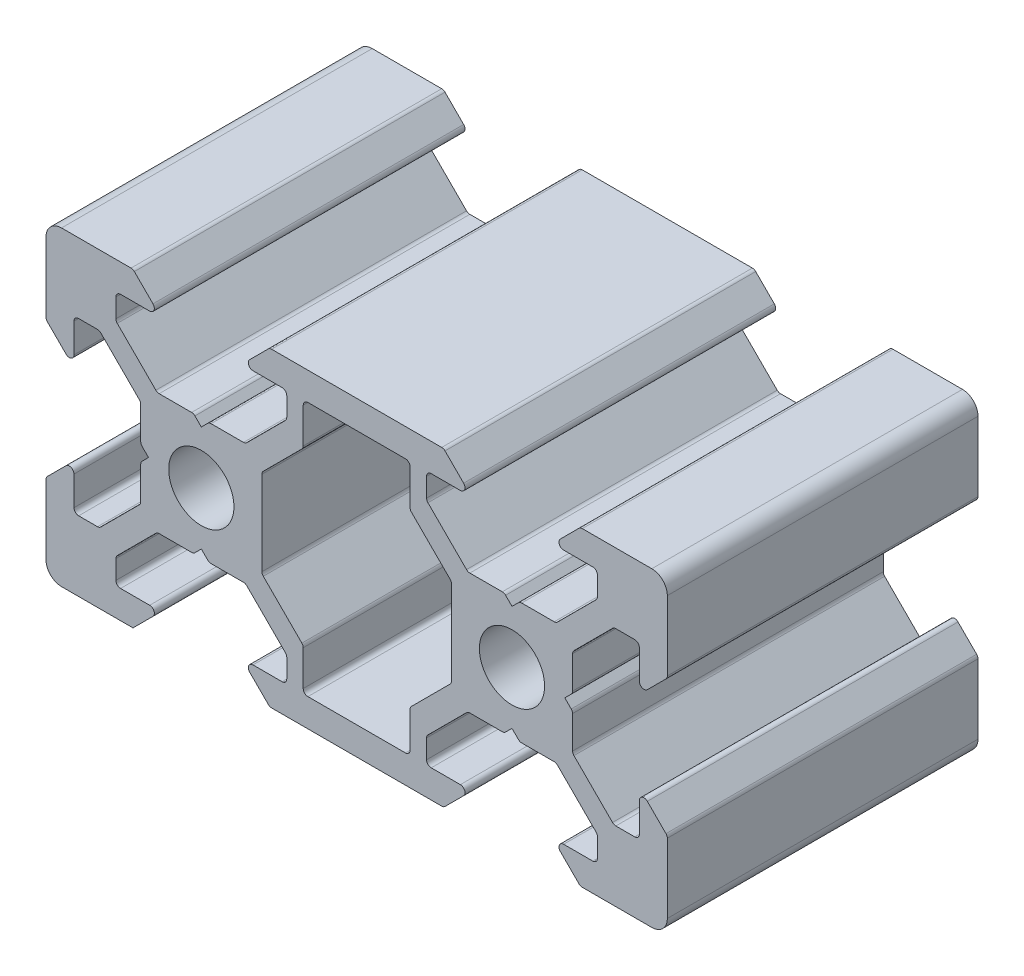
from build123d import *

# Parameters (mm, degrees)
SKETCH_1_R      = 2.1
EXTRUDE_1_DEPTH = 20
FILLET_1_R      = 1
FILLET_2_R      = 0.3


with BuildPart() as part:
    # Эскиз1 → Бобышка-Вытянуть1 (new body)
    with BuildSketch(Plane.XY):
        Polygon((-10, -10), (-10, -4.4), (-8.2, -2.6), (-8.2, -5.499339828), (-6.56, -5.499339828), (-3.900660172, -2.84), (-3.900660172, -0.5), (-3.400660172, 0), (-3.900660172, 0.5), (-3.900660172, 2.84), (-6.56, 5.499339828), (-8.2, 5.499339828), (-8.2, 2.6), (-10, 4.4), (-10, 10), (-4.4, 10), (-2.6, 8.2), (-5.499339828, 8.2), (-5.499339828, 6.56), (-2.84, 3.900660172), (-0.5, 3.900660172), (0, 3.400660172), (0.5, 3.900660172), (2.84, 3.900660172), (5.499339828, 6.56), (5.499339828, 8.2), (2.6, 8.2), (4.4, 10), (15.6, 10), (17.4, 8.2), (14.500660172, 8.2), (14.500660172, 6.56), (17.16, 3.900660172), (19.5, 3.900660172), (20, 3.400660172), (20.5, 3.900660172), (22.84, 3.900660172), (25.499339828, 6.56), (25.499339828, 8.2), (22.6, 8.2), (24.4, 10), (30, 10), (30, 4.4), (28.2, 2.6), (28.2, 5.499339828), (26.56, 5.499339828), (23.900660172, 2.84), (23.900660172, 0.5), (23.400660172, 0), (23.900660172, -0.5), (23.900660172, -2.84), (26.56, -5.499339828), (28.2, -5.499339828), (28.2, -2.6), (30, -4.4), (30, -10), (24.4, -10), (22.6, -8.2), (25.499339828, -8.2), (25.499339828, -6.56), (22.84, -3.900660172), (20.5, -3.900660172), (20, -3.400660172), (19.5, -3.900660172), (17.16, -3.900660172), (14.500660172, -6.56), (14.500660172, -8.2), (17.4, -8.2), (15.6, -10), (4.4, -10), (2.6, -8.2), (5.499339828, -8.2), (5.499339828, -6.56), (2.84, -3.900660172), (0.5, -3.900660172), (0, -3.400660172), (-0.5, -3.900660172), (-2.84, -3.900660172), (-5.499339828, -6.56), (-5.499339828, -8.2), (-2.6, -8.2), (-4.4, -10), align=None)
        Circle(SKETCH_1_R, mode=Mode.SUBTRACT)
        with Locations(Location((20, 0, 0), (0, 0, 180))):  # turned: the seam where the file's is
            Circle(SKETCH_1_R, mode=Mode.SUBTRACT)
        Polygon((3.900660172, -0.5), (3.900660172, 0.5), (3.900660172, 2.84), (6.56, 5.499339828), (6.56, 8.2), (13.44, 8.2), (13.44, 5.499339828), (16.099339828, 2.84), (16.099339828, 0.5), (16.099339828, -0.5), (16.099339828, -2.84), (13.44, -5.499339828), (13.44, -8.2), (6.56, -8.2), (6.56, -5.499339828), (3.900660172, -2.84), align=None, mode=Mode.SUBTRACT)
    extrude(amount=EXTRUDE_1_DEPTH)

    # Скругление1
    fillet_1_edges = [part.edges().sort_by_distance(p)[0] for p in [
        (-10, -10, 10),
        (-10, 10, 10),
        (30, 10, 10),
        (30, -10, 10),
    ]]
    fillet(fillet_1_edges, radius=FILLET_1_R)

    # Скругление2
    fillet_2_edges = [part.edges().sort_by_distance(p)[0] for p in [
        (-10, -4.4, 10),
        (-8.2, -2.6, 10),
        (-8.2, -5.499339828, 10),
        (-6.56, -5.499339828, 10),
        (-3.900660172, -2.84, 10),
        (-3.900660172, -0.5, 10),
        (-3.900660172, 0.5, 10),
        (-3.900660172, 2.84, 10),
        (-6.56, 5.499339828, 10),
        (-8.2, 5.499339828, 10),
        (-8.2, 2.6, 10),
        (-10, 4.4, 10),
        (-4.4, 10, 10),
        (-2.6, 8.2, 10),
        (-5.499339828, 8.2, 10),
        (-5.499339828, 6.56, 10),
        (-2.84, 3.900660172, 10),
        (-0.5, 3.900660172, 10),
        (0.5, 3.900660172, 10),
        (2.84, 3.900660172, 10),
        (5.499339828, 6.56, 10),
        (5.499339828, 8.2, 10),
        (2.6, 8.2, 10),
        (4.4, 10, 10),
        (15.6, 10, 10),
        (17.4, 8.2, 10),
        (14.500660172, 8.2, 10),
        (14.500660172, 6.56, 10),
        (17.16, 3.900660172, 10),
        (19.5, 3.900660172, 10),
        (20.5, 3.900660172, 10),
        (22.84, 3.900660172, 10),
        (25.499339828, 6.56, 10),
        (25.499339828, 8.2, 10),
        (22.6, 8.2, 10),
        (24.4, 10, 10),
        (30, 4.4, 10),
        (28.2, 2.6, 10),
        (28.2, 5.499339828, 10),
        (26.56, 5.499339828, 10),
        (23.900660172, 2.84, 10),
        (23.900660172, 0.5, 10),
        (23.900660172, -0.5, 10),
        (23.900660172, -2.84, 10),
        (26.56, -5.499339828, 10),
        (28.2, -5.499339828, 10),
        (28.2, -2.6, 10),
        (30, -4.4, 10),
        (24.4, -10, 10),
        (22.6, -8.2, 10),
        (25.499339828, -8.2, 10),
        (25.499339828, -6.56, 10),
        (22.84, -3.900660172, 10),
        (20.5, -3.900660172, 10),
        (19.5, -3.900660172, 10),
        (17.16, -3.900660172, 10),
        (14.500660172, -6.56, 10),
        (14.500660172, -8.2, 10),
        (17.4, -8.2, 10),
        (15.6, -10, 10),
        (4.4, -10, 10),
        (2.6, -8.2, 10),
        (5.499339828, -8.2, 10),
        (5.499339828, -6.56, 10),
        (2.84, -3.900660172, 10),
        (0.5, -3.900660172, 10),
        (-0.5, -3.900660172, 10),
        (-2.84, -3.900660172, 10),
        (-5.499339828, -6.56, 10),
        (-5.499339828, -8.2, 10),
        (-2.6, -8.2, 10),
        (6.56, -8.2, 10),
        (13.44, -8.2, 10),
        (13.44, -5.499339828, 10),
        (16.099339828, -2.84, 10),
        (16.099339828, 2.84, 10),
        (13.44, 5.499339828, 10),
        (13.44, 8.2, 10),
        (6.56, 8.2, 10),
        (6.56, 5.499339828, 10),
        (3.900660172, 2.84, 10),
        (3.900660172, -2.84, 10),
        (6.56, -5.499339828, 10),
    ]]
    fillet(fillet_2_edges, radius=FILLET_2_R)


solid = part.part
